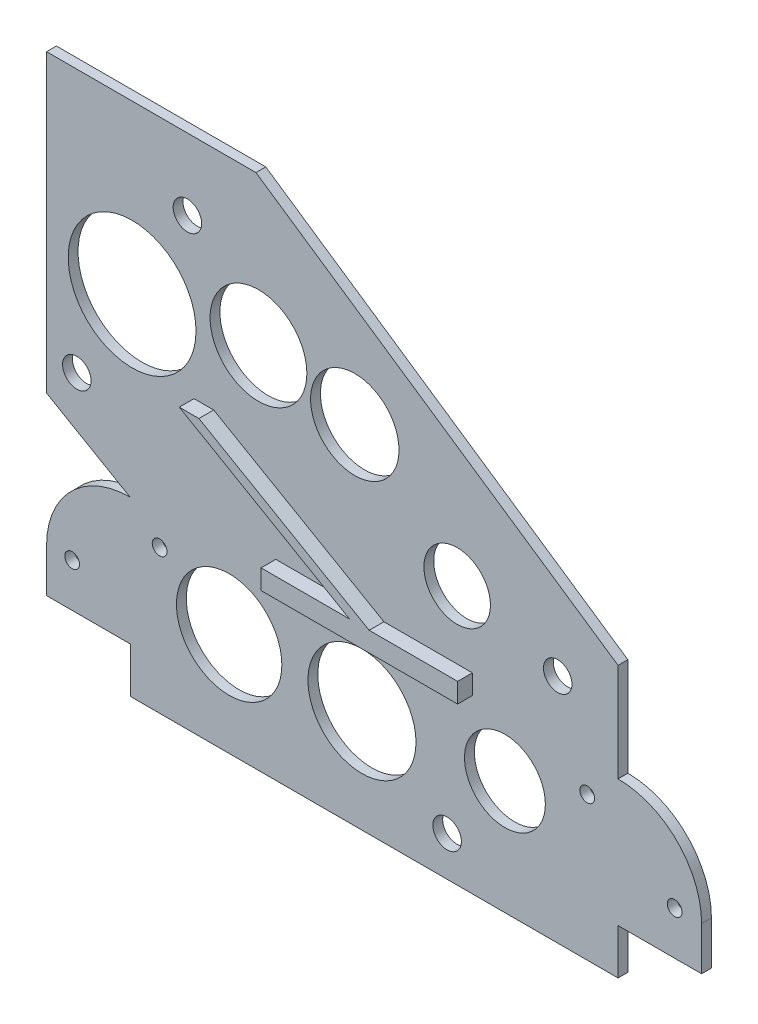
from build123d import *

# Parameters (mm, degrees)
SKETCH_1_R          = 1.5
SKETCH_1_R_2        = 2.9
SKETCH_1_R_3        = 13
EXTRUDE_2_DEPTH     = 2
EXTRUDE_3_DEPTH     = 3
SKETCH_3_R          = 9.847727686
SKETCH_3_R_2        = 8.997097943
SKETCH_3_R_3        = 10.721268195
SKETCH_3_R_4        = 10.991913459
SKETCH_3_R_5        = 8.225176043
SKETCH_3_R_6        = 6.770172336
CUT_EXTRUDE_1_DEPTH = 3


with BuildPart() as part:
    # 草图1 → 凸台-拉伸2 (new body)
    with BuildSketch(Plane.XY):
        with BuildLine():
            Line((49.779367134, 18.85), (49.779367134, 38.85))
            Line((49.779367134, 38.85), (-23.899828069, 88.85))
            Line((-23.899828069, 88.85), (-66.5, 88.85))
            Line((-66.5, 88.85), (-66.5, 28.68453606))
            Line((-66.5, 28.68453606), (-60.610760184, 25.264800383))
            Line((-60.610760184, 25.264800383), (-49.5, 18.85))
            ThreePointArc((-49.5, 18.85), (-61.52081528, 13.87081528), (-66.5, 1.85))
            Line((-66.5, 1.85), (-66.5, -7))
            Line((-66.5, -7), (-49.450486279, -7))
            Line((-49.450486279, -7), (-49.450486279, -16.236884808))
            Line((-49.450486279, -16.236884808), (49.779367134, -16.236884808))
            Line((49.779367134, -16.236884808), (49.779367134, -7))
            Line((49.779367134, -7), (66.779367134, -7))
            Line((66.779367134, -7), (66.779367134, 1.85))
            ThreePointArc((66.779367134, 1.85), (61.800182415, 13.87081528), (49.779367134, 18.85))
        make_face()
        with Locations((-61.3, 1.85)):
            Circle(SKETCH_1_R, mode=Mode.SUBTRACT)
        with Locations((-43.5, 13)):
            Circle(SKETCH_1_R, mode=Mode.SUBTRACT)
        with Locations((15, -8.15)):
            Circle(SKETCH_1_R_2, mode=Mode.SUBTRACT)
        with Locations((37.5, 30.82114317)):
            Circle(SKETCH_1_R_2, mode=Mode.SUBTRACT)
        with Locations((-60.344210129, 35.35)):
            Circle(SKETCH_1_R_2, mode=Mode.SUBTRACT)
        with Locations((-37.844210129, 74.32114317)):
            Circle(SKETCH_1_R_2, mode=Mode.SUBTRACT)
        with Locations((43.5, 13)):
            Circle(SKETCH_1_R, mode=Mode.SUBTRACT)
        with Locations((61.3, 1.85)):
            Circle(SKETCH_1_R, mode=Mode.SUBTRACT)
        with Locations((-49.094210129, 54.835571585)):
            Circle(SKETCH_1_R_3, mode=Mode.SUBTRACT)
    extrude(amount=EXTRUDE_2_DEPTH)

    # 草图2 → 凸台-拉伸3 (add)
    with BuildSketch(Plane.XY.offset(2)):
        Polygon((-1.860316433, 22.713601471), (-36.501332584, 42.713601471), (-32.501332584, 42.713601471), (2.139683567, 22.713601471), (20.139683567, 22.713601471), (20.139683567, 18.713601471), (2.139683567, 18.713601471), (-1.860316433, 18.713601471), (-19.860316433, 18.713601471), (-19.860316433, 22.713601471), align=None)
    extrude(amount=EXTRUDE_3_DEPTH)

    # 草图3 → 切除-拉伸1 (cut, through all)
    with BuildSketch(Plane.XY.offset(2)):
        with Locations((-23.384871699, 58.634182407)):
            Circle(SKETCH_3_R)
        with Locations((-3.787476222, 54.505622136)):
            Circle(SKETCH_3_R_2)
        with Locations((-29.351202297, 4.727480211)):
            Circle(SKETCH_3_R_3)
        with Locations((-2.325708947, 4.727480211)):
            Circle(SKETCH_3_R_4)
        with Locations((26.76200458, 6.974994395)):
            Circle(SKETCH_3_R_5)
        with Locations((17.040896101, 36.475624713)):
            Circle(SKETCH_3_R_6)
    extrude(amount=-CUT_EXTRUDE_1_DEPTH, mode=Mode.SUBTRACT)


solid = part.part
